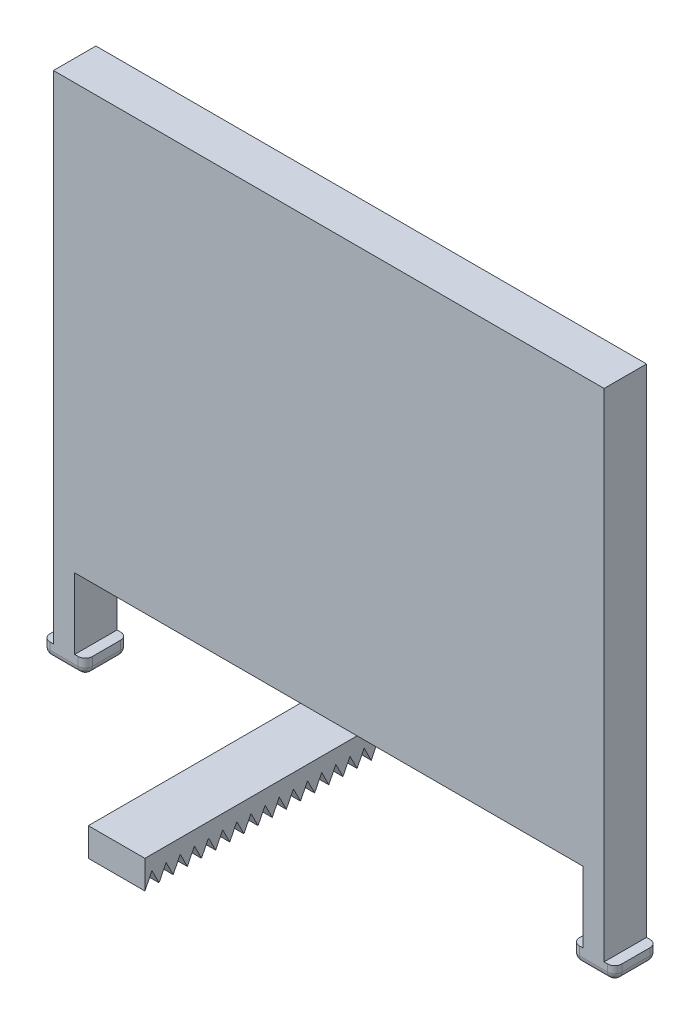
from build123d import *

# Parameters (mm, degrees)
Y_KSEKLIK_EKSTR_ZYON1_DEPTH = 3
IZIM2_W                     = 4
IZIM2_H                     = 2
Y_KSEKLIK_EKSTR_ZYON2_DEPTH = 15
KES_EKSTR_ZYON1_DEPTH       = 15
KES_EKSTR_ZYON2_DEPTH       = 10
RADYUS5_R                   = 0.5
RADYUS6_R                   = 0.5
RADYUS7_R                   = 0.5
RADYUS8_R                   = 0.5


with BuildPart() as part:
    # Çizim1 → Yükseklik-Ekstrüzyon1 (new body)
    with BuildSketch(Plane.XY):
        Polygon((-19.370820864, 54.614030312), (19.558307899, 54.614030312), (19.558307899, 19.505544156), (20.308307899, 19.505544156), (20.308307899, 18.505544156), (17.308307899, 18.505544156), (17.308307899, 19.614030312), (18.058307899, 19.614030312), (18.058307899, 24.614030312), (-17.870820864, 24.614030312), (-17.870820864, 19.614030312), (-17.120820864, 19.614030312), (-17.120820864, 18.505544156), (-20.120820864, 18.505544156), (-20.120820864, 19.505544156), (-19.370820864, 19.505544156), align=None)
    extrude(amount=Y_KSEKLIK_EKSTR_ZYON1_DEPTH)

    # Çizim2 → Yükseklik-Ekstrüzyon2 (add, symmetric)
    with BuildSketch(Plane.XY.offset(3)):
        with Locations((0.094179136, 23.614030312)):
            Rectangle(IZIM2_W, IZIM2_H)
    extrude(amount=Y_KSEKLIK_EKSTR_ZYON2_DEPTH, both=True)

    # Çizim3 → Kes-Ekstrüzyon1 (cut)
    with BuildSketch(Plane(origin=(2.094179136, 0, 0), x_dir=(0, 0, -1), z_dir=(1, 0, 0))):
        Polygon((-3, 22.614030312), (-2, 22.614030312), (-2.5, 23.614030312), align=None)
        Polygon((-2, 22.614030312), (-1, 22.614030312), (-1.5, 23.614030312), align=None)
        Polygon((2, 22.614030312), (3, 22.614030312), (2.5, 23.614030312), align=None)
        Polygon((3, 22.614030312), (4, 22.614030312), (3.5, 23.614030312), align=None)
        Polygon((4, 22.614030312), (5, 22.614030312), (4.5, 23.614030312), align=None)
        Polygon((5, 22.614030312), (6, 22.614030312), (5.5, 23.614030312), align=None)
        Polygon((7, 22.614030312), (8, 22.614030312), (7.5, 23.614030312), align=None)
        Polygon((8, 22.614030312), (9, 22.614030312), (8.5, 23.614030312), align=None)
        Polygon((9, 22.614030312), (10, 22.614030312), (9.5, 23.614030312), align=None)
        Polygon((11, 22.614030312), (10.5, 23.614030312), (10, 22.614030312), align=None)
        Polygon((11.5, 23.614030312), (11, 22.614030312), (12, 22.614030312), align=None)
        Polygon((-0.5, 23.614030312), (0, 22.614030312), (-1, 22.614030312), align=None)
        Polygon((0.5, 23.614030312), (1, 22.614030312), (0, 22.614030312), align=None)
        Polygon((1.5, 23.614030312), (2, 22.614030312), (1, 22.614030312), align=None)
        Polygon((6.5, 23.614030312), (7, 22.614030312), (6, 22.614030312), align=None)
    extrude(amount=-KES_EKSTR_ZYON1_DEPTH, mode=Mode.SUBTRACT)

    # Çizim4 → Kes-Ekstrüzyon2 (cut)
    with BuildSketch(Plane(origin=(2.094179136, 0, 0), x_dir=(0, 0, -1), z_dir=(1, 0, 0))):
        Polygon((-11, 22.614030312), (-10, 22.614030312), (-10.5, 23.614030312), align=None)
        Polygon((-9, 22.614030312), (-8, 22.614030312), (-8.5, 23.614030312), align=None)
        Polygon((-17, 22.614030312), (-18, 22.614030312), (-17.5, 23.614030312), align=None)
        Polygon((-16, 22.614030312), (-17, 22.614030312), (-16.5, 23.614030312), align=None)
        Polygon((-15, 22.614030312), (-16, 22.614030312), (-15.5, 23.614030312), align=None)
        Polygon((-14, 22.614030312), (-15, 22.614030312), (-14.5, 23.614030312), align=None)
        Polygon((-13, 22.614030312), (-14, 22.614030312), (-13.5, 23.614030312), align=None)
        Polygon((-12, 22.614030312), (-13, 22.614030312), (-12.5, 23.614030312), align=None)
        Polygon((-11.5, 23.614030312), (-11, 22.614030312), (-12, 22.614030312), align=None)
        Polygon((-9, 22.614030312), (-10, 22.614030312), (-9.5, 23.614030312), align=None)
        Polygon((-7, 22.614030312), (-8, 22.614030312), (-7.5, 23.614030312), align=None)
        Polygon((-6, 22.614030312), (-7, 22.614030312), (-6.5, 23.614030312), align=None)
        Polygon((-5, 22.614030312), (-6, 22.614030312), (-5.5, 23.614030312), align=None)
        Polygon((-4, 22.614030312), (-5, 22.614030312), (-4.5, 23.614030312), align=None)
        Polygon((-3, 22.614030312), (-4, 22.614030312), (-3.5, 23.614030312), align=None)
        Polygon((-2, 22.614030312), (-3, 22.614030312), (-2.5, 23.614030312), align=None)
        Polygon((-2, 22.614030312), (-1.5, 23.614030312), (-1, 22.614030312), align=None)
        Polygon((0, 22.614030312), (-1, 22.614030312), (-0.5, 23.614030312), align=None)
        Polygon((1, 22.614030312), (0, 22.614030312), (0.5, 23.614030312), align=None)
    extrude(amount=-KES_EKSTR_ZYON2_DEPTH, mode=Mode.SUBTRACT)

    # Radyus5
    radyus5_edges = [part.edges().sort_by_distance(p)[0] for p in [
        (18.808307899, 18.505544156, 0),
        (18.808307899, 18.505544156, 3),
    ]]
    fillet(radyus5_edges, radius=RADYUS5_R)

    # Radyus6
    radyus6_edges = [part.edges().sort_by_distance(p)[0] for p in [
        (-18.620820864, 18.505544156, 3),
        (-18.620820864, 18.505544156, 0),
    ]]
    fillet(radyus6_edges, radius=RADYUS6_R)

    # Radyus7
    radyus7_edges = [part.edges().sort_by_distance(p)[0] for p in [
        (-20.120820864, 19.255544156, 3),
        (-20.120820864, 19.255544156, 0),
        (-17.120820864, 18.505544156, 1.5),
        (-20.120820864, 18.505544156, 1.5),
        (-17.120820864, 19.309787234, 0),
        (-17.120820864, 19.309787234, 3),
        (-17.120820864, 18.651990766, 2.853553391),
        (-17.120820864, 18.651990766, 0.146446609),
        (-20.120820864, 18.651990766, 2.853553391),
        (-20.120820864, 18.651990766, 0.146446609),
    ]]
    fillet(radyus7_edges, radius=RADYUS7_R)

    # Radyus8
    radyus8_edges = [part.edges().sort_by_distance(p)[0] for p in [
        (17.308307899, 19.309787234, 0),
        (17.308307899, 19.309787234, 3),
        (20.308307899, 18.505544156, 1.5),
        (17.308307899, 18.505544156, 1.5),
        (20.308307899, 19.255544156, 0),
        (20.308307899, 19.255544156, 3),
        (20.308307899, 18.651990766, 2.853553391),
        (20.308307899, 18.651990766, 0.146446609),
        (17.308307899, 18.651990766, 2.853553391),
        (17.308307899, 18.651990766, 0.146446609),
    ]]
    fillet(radyus8_edges, radius=RADYUS8_R)


solid = part.part
